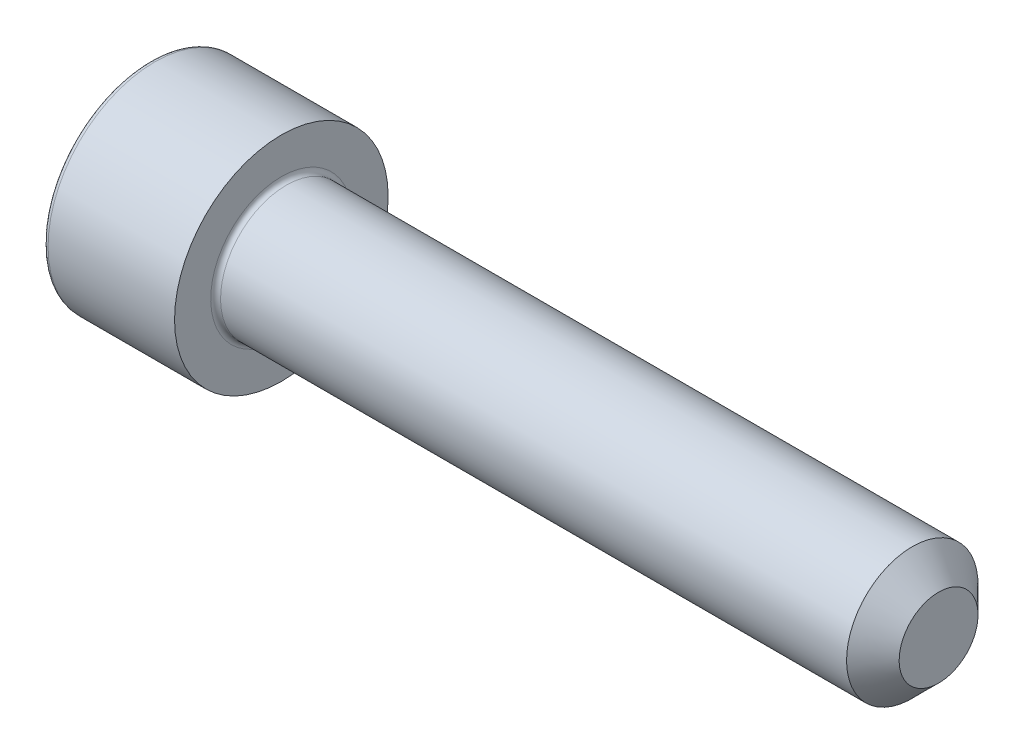
from build123d import *

# Parameters (mm, degrees)
CUT_EXTRUDE_1_DEPTH = 2.5
FILLET_1_R          = 0.3
CHAMFER_1_SIZE      = 1.6


with BuildPart() as part:
    # Эскиз1 → Повернуть1 (revolve)
    with BuildSketch(Plane.XY):
        Polygon((0, 0), (0, 6.5), (8, 6.5), (8, 4), (48, 4), (48, 0), align=None)
    revolve(axis=Axis((48, 0, 0), (-1, 0, 0)))

    # Эскиз2 → Вырез-Вытянуть1 (cut)
    with BuildSketch(Plane.ZY):
        Polygon((-1.732050808, 3), (-3.464101615, 0), (-1.732050808, -3), (1.732050808, -3), (3.464101615, 0), (1.732050808, 3), align=None)
    extrude(amount=-CUT_EXTRUDE_1_DEPTH, mode=Mode.SUBTRACT)

    # Скругление1
    fillet_1_edges = [part.edges().sort_by_distance(p)[0] for p in [
        (8, -4, 0),
        (0, -6.5, 0),
    ]]
    fillet(fillet_1_edges, radius=FILLET_1_R)

    # Фаска1
    chamfer_1_edges = [part.edges().sort_by_distance(p)[0] for p in [
        (48, -4, 0),
    ]]
    chamfer(chamfer_1_edges, length=CHAMFER_1_SIZE)


solid = part.part
